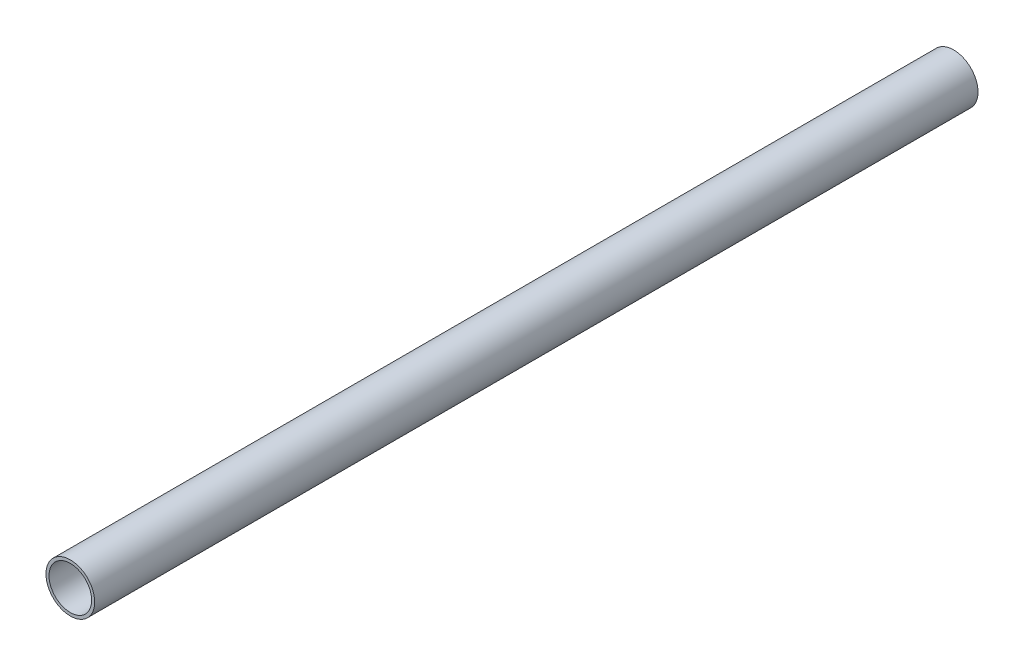
from build123d import *

# Parameters (mm, degrees)
BOSS_EXTRUDE1_DEPTH      = 260
BOSS_EXTRUDE1_DEPTH_BACK = 30
SKETCH1_R                = 8
SKETCH1_R_2              = 7


with BuildPart() as part:
    # Sketch1 → Boss-Extrude1 (new, two sides: drawn at the far end of the back side and taken through both)
    with BuildSketch(Plane.XY.offset(-BOSS_EXTRUDE1_DEPTH_BACK)):
        Circle(SKETCH1_R)
        Circle(SKETCH1_R_2, mode=Mode.SUBTRACT)
    extrude(amount=BOSS_EXTRUDE1_DEPTH + BOSS_EXTRUDE1_DEPTH_BACK)


solid = part.part
